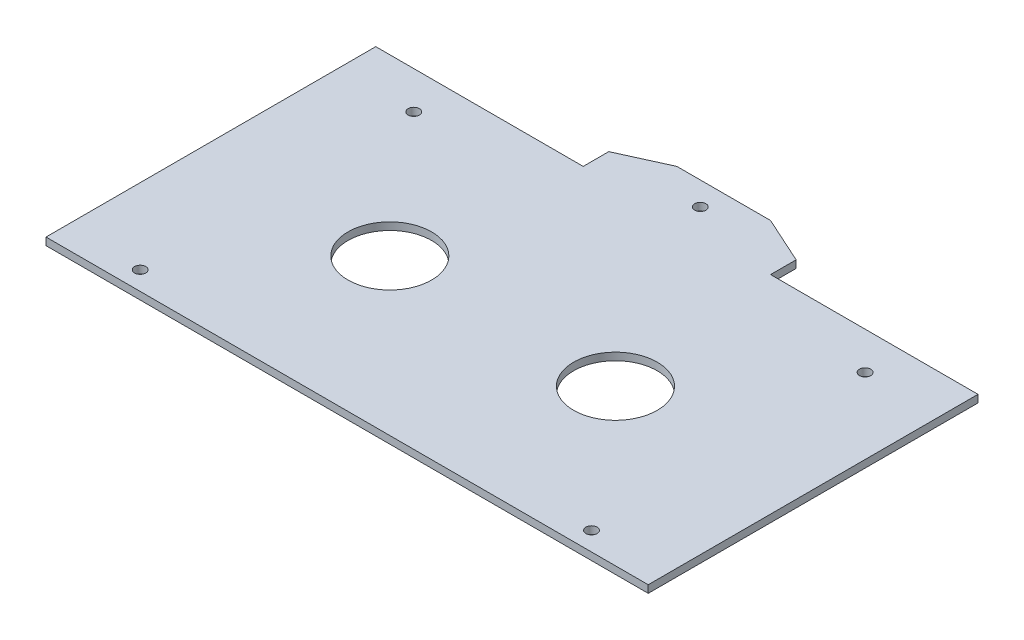
from build123d import *

# Parameters (mm, degrees)
SKETCH1_W           = 155.702807198
SKETCH1_H           = 58
SKETCH1_R           = 1.5
BOSS_EXTRUDE2_DEPTH = 2
SKETCH2_W           = 5
SKETCH2_H           = 88
BOSS_EXTRUDE3_DEPTH = 2
SKETCH3_R           = 11.15
CUT_EXTRUDE1_DEPTH  = 10
SKETCH4_R           = 1.5
BOSS_EXTRUDE4_DEPTH = 2
SKETCH7_W           = 1.5
SKETCH7_H           = 88
SKETCH7_H_2         = 87.852132556
CUT_EXTRUDE2_DEPTH  = 10
SKETCH8_W           = 0.36402546
SKETCH8_H           = 0.147867444
SKETCH8_W_2         = 1.5
SKETCH8_W_3         = 1
SKETCH8_H_2         = 88
CUT_EXTRUDE5_DEPTH  = 66.5


with BuildPart() as part:
    # Sketch1 → Boss-Extrude2 (new body)
    with BuildSketch(Plane(origin=(0, 0, 0), x_dir=(1, 0, 0), z_dir=(0, 1, 0))):
        with Locations((1.171695753, -5)):
            Rectangle(SKETCH1_W, SKETCH1_H)
        Polygon((-76.679707846, 44), (-76.679707846, 24), (79.023099352, 24), (79.023099352, 44), (62.885457038, 44), (59.885457038, 44), (-57.542065533, 44), (-60.542065533, 44), align=None)
        with Locations((-59.042065533, 34)):
            Circle(SKETCH1_R, mode=Mode.SUBTRACT)
        with Locations((61.385457038, 34)):
            Circle(SKETCH1_R, mode=Mode.SUBTRACT)
        Polygon((-76.679707846, -44), (-60.542065533, -44), (-57.542065533, -44), (59.885457038, -44), (62.885457038, -44), (79.023099352, -44), (79.023099352, -34), (-76.679707846, -34), align=None)
        with Locations((-59.042065533, -39)):
            Circle(SKETCH1_R, mode=Mode.SUBTRACT)
        with Locations((61.385457038, -39)):
            Circle(SKETCH1_R, mode=Mode.SUBTRACT)
    extrude(amount=BOSS_EXTRUDE2_DEPTH)

    # Sketch2 → Boss-Extrude3 (add)
    with BuildSketch(Plane(origin=(0, 2, 0), x_dir=(1, 0, 0), z_dir=(0, 1, 0))):
        with Locations((81.523099352, 0)):
            Rectangle(SKETCH2_W, SKETCH2_H)
        with Locations((-79.179707846, 0)):
            Rectangle(SKETCH2_W, SKETCH2_H)
    extrude(amount=-BOSS_EXTRUDE3_DEPTH)

    # Sketch3 → Cut-Extrude1 (cut)
    with BuildSketch(Plane(origin=(0, 2, 0), x_dir=(1, 0, 0), z_dir=(0, 1, 0))):
        with Locations((-28.93518489, -2.5)):
            Circle(SKETCH3_R)
        with Locations((31.278576395, -2.5)):
            Circle(SKETCH3_R)
    extrude(amount=-CUT_EXTRUDE1_DEPTH, mode=Mode.SUBTRACT)

    # Sketch4 → Boss-Extrude4 (add)
    with BuildSketch(Plane(origin=(0, 2, 0), x_dir=(1, 0, 0), z_dir=(0, 1, 0))):
        Polygon((-23.828304247, 44), (26.171695753, 44), (26.171695753, 50.823606938), (13.671695753, 56.49492606), (-11.328304247, 56.49492606), (-23.828304247, 50.823606938), align=None)
        with Locations((1.171695753, 50.24746303)):
            Circle(SKETCH4_R, mode=Mode.SUBTRACT)
    extrude(amount=-BOSS_EXTRUDE4_DEPTH)

    # Sketch7 → Cut-Extrude2 (cut)
    with BuildSketch(Plane(origin=(0, 2, 0), x_dir=(1, 0, 0), z_dir=(0, 1, 0))):
        with Locations((-80.929707846, 0)):
            Rectangle(SKETCH7_W, SKETCH7_H)
        with Locations((83.273099352, 0.073933722)):
            Rectangle(SKETCH7_W, SKETCH7_H_2)
    extrude(amount=-CUT_EXTRUDE2_DEPTH, mode=Mode.SUBTRACT)

    # Sketch8 → Cut-Extrude5 (cut)
    with BuildSketch(Plane(origin=(0, 2, 0), x_dir=(1, 0, 0), z_dir=(0, 1, 0))):
        with Locations((82.341086622, -43.926066278)):
            Rectangle(SKETCH8_W, SKETCH8_H)
        with Locations((83.273099352, -43.926066278)):
            Rectangle(SKETCH8_W_2, SKETCH8_H)
        Polygon((81.523099352, 44), (81.523099352, -44), (82.159073892, -44), (82.159073892, -43.852132556), (82.523099352, -43.852132556), (82.523099352, 44), align=None)
        with Locations((-79.679707846, 0)):
            Rectangle(SKETCH8_W_3, SKETCH8_H_2)
    extrude(amount=-CUT_EXTRUDE5_DEPTH, mode=Mode.SUBTRACT)


solid = part.part
